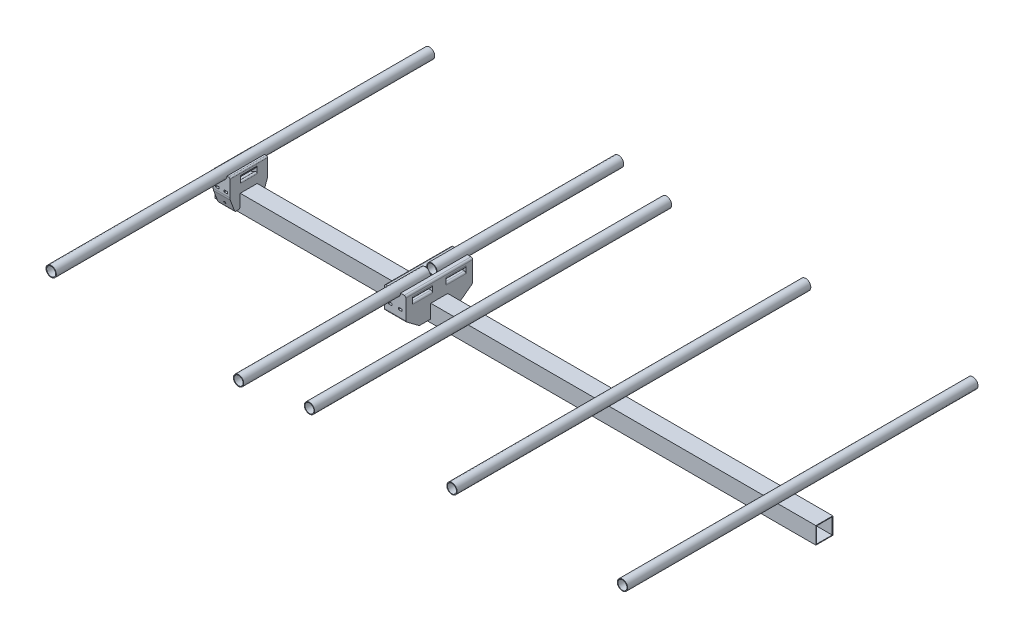
from build123d import *

# Parameters (mm, degrees)
SKETCH1_W                                      = 25.4
SKETCH1_H                                      = 25.4
SKETCH1_W_2                                    = 23.622
SKETCH1_H_2                                    = 23.622
AL_TUBE_SQUARE_AL_TUBE_1_SQR_X_0_035_WAL_DEPTH = 900
ELEMENT_GEOMETRY_R                             = 7.75
REFLECTOR_GEOMETRY_DEPTH                       = 283.5
ELEMENT_GEOMETRY_4_R                           = 7.75
DIRECTOR_GEOMETRY_1_DEPTH                      = 267.5
ELEMENT_GEOMETRY_5_R                           = 7.75
DIRECTOR_GEOMETRY_2_DEPTH                      = 265
ELEMENT_GEOMETRY_6_R                           = 7.75
DIRECTOR_GEOMETRY_3_DEPTH                      = 262.5
DIPOLE_A_START                                 = 5
ELEMENT_GEOMETRY_7_R                           = 7.75
DIPOLE_A_DEPTH                                 = 279.7
ELEMENT_BASE_DEPTH                             = 13.2
ELEMENT_BASE_DEPTH_BACK                        = 13.2
ELEMENT_BASE_SIDE_DEPTH                        = 15
CUT_EXTRUDE3_DEPTH                             = 12.5
SKETCH9_R                                      = 1.5
CUT_EXTRUDE4_DEPTH                             = 551.208733119
CUT_EXTRUDE4_DEPTH_BACK                        = 551.208733119
SKETCH10_W                                     = 5
SKETCH10_H                                     = 3
CUT_EXTRUDE5_DEPTH                             = 56.4
CUT_EXTRUDE6_DEPTH                             = 25
FILLET3_R                                      = 10
FILLET4_R                                      = 2
DIRECTOR_BASE_R                                = 2
BOSS_EXTRUDE8_DEPTH                            = 50
BOSS_EXTRUDE10_START                           = -127
BOSS_EXTRUDE10_DEPTH                           = 32
BOSS_EXTRUDE11_DEPTH                           = 32
BOSS_EXTRUDE11_2_DEPTH                         = 32
SKETCH18_W                                     = 30
SKETCH18_H                                     = 3
CUT_EXTRUDE7_DEPTH                             = 32
FILLET6_R                                      = 5
FILLET7_R                                      = 2.5
SKETCH21_W                                     = 5
SKETCH21_H                                     = 3
CUT_EXTRUDE8_DEPTH                             = 535.674976037
CUT_EXTRUDE8_DEPTH_BACK                        = 535.674976037
CUT_EXTRUDE10_DEPTH                            = 32
DIPOLE_BASE_R                                  = 2.5
SKETCH24_R                                     = 6.75
CUT_EXTRUDE11_DEPTH                            = 535.674976037
CUT_EXTRUDE11_DEPTH_BACK                       = 535.674976037


with BuildPart() as part:
    # Sketch1 → Al tube square AL TUBE 1 SQR X 0.035 WAL (new body)
    with BuildSketch(Plane(origin=(-450, 0, 0), x_dir=(0, 0, -1), z_dir=(1, 0, 0))):
        Rectangle(SKETCH1_W, SKETCH1_H)
        Rectangle(SKETCH1_W_2, SKETCH1_H_2, mode=Mode.SUBTRACT)
    extrude(amount=AL_TUBE_SQUARE_AL_TUBE_1_SQR_X_0_035_WAL_DEPTH)


with BuildPart() as body_2:
    # Element Geometry → Reflector Geometry (new, symmetric)
    with BuildSketch(Plane.XY):
        with Locations((-425, 40.45)):
            Circle(ELEMENT_GEOMETRY_R)
    extrude(amount=REFLECTOR_GEOMETRY_DEPTH, both=True)


with BuildPart() as body_3:
    # Element Geometry_4 → Director Geometry _1 (new, symmetric)
    with BuildSketch(Plane.XY):
        with Locations((-54, 40.45)):
            Circle(ELEMENT_GEOMETRY_4_R)
    extrude(amount=DIRECTOR_GEOMETRY_1_DEPTH, both=True)


with BuildPart() as body_4:
    # Element Geometry_5 → Director Geometry _2 (new, symmetric)
    with BuildSketch(Plane.XY):
        with Locations((157, 40.45)):
            Circle(ELEMENT_GEOMETRY_5_R)
    extrude(amount=DIRECTOR_GEOMETRY_2_DEPTH, both=True)


with BuildPart() as body_5:
    # Element Geometry_6 → Director Geometry _3 (new, symmetric)
    with BuildSketch(Plane.XY):
        with Locations((410, 40.45)):
            Circle(ELEMENT_GEOMETRY_6_R)
    extrude(amount=DIRECTOR_GEOMETRY_3_DEPTH, both=True)


with BuildPart() as body_6:
    # Element Geometry_7 → Dipole-A (new body)
    with BuildSketch(Plane.XY.offset(DIPOLE_A_START)):
        with Locations((-143, 40.45)):
            Circle(ELEMENT_GEOMETRY_7_R)
    extrude(amount=DIPOLE_A_DEPTH)


with BuildPart() as body_7:
    # Dipole-B: mirrored copy
    add(body_6.part.mirror(Plane.XY))


with BuildPart() as body_8:
    # Sketch3 → Element Base (new, two sides)
    with BuildSketch(Plane.XY) as element_base_sk:
        with BuildLine():
            Line((-433, 40.45), (-437.5, 40.45))
            Line((-437.5, 40.45), (-437.5, 12.7))
            Line((-437.5, 12.7), (-412.5, 12.7))
            Line((-412.5, 12.7), (-412.5, 40.45))
            Line((-412.5, 40.45), (-417, 40.45))
            ThreePointArc((-417, 40.45), (-425, 32.45), (-433, 40.45))
        make_face()
    extrude(amount=ELEMENT_BASE_DEPTH)
    extrude(element_base_sk.sketch, amount=-ELEMENT_BASE_DEPTH_BACK)


with BuildPart() as body_9:
    # Sketch4 → Element Base Side (new body)
    with BuildSketch(Plane.XY.offset(13.2)):
        with BuildLine():
            Line((-437.5, 12.7), (-437.5, -7.3))
            Line((-437.5, -7.3), (-412.5, -7.3))
            Line((-412.5, -7.3), (-412.5, 12.7))
            Line((-412.5, 12.7), (-412.5, 40.45))
            Line((-412.5, 40.45), (-417, 40.45))
            ThreePointArc((-417, 40.45), (-425, 32.45), (-433, 40.45))
            Line((-433, 40.45), (-437.5, 40.45))
            Line((-437.5, 40.45), (-437.5, 12.7))
        make_face()
    extrude(amount=ELEMENT_BASE_SIDE_DEPTH)


with BuildPart() as body_10:
    # Mirror3: mirrored copy
    add(body_9.part.mirror(Plane.XY))

    # Combine1: union body 8, body 9
    add(body_8.part)
    add(body_9.part)

    # Sketch8 → Cut-Extrude3 (cut, symmetric)
    with BuildSketch(Plane.XY):
        with BuildLine():
            Line((-412.5, 35.45), (-412.5, 29.736575146))
            ThreePointArc((-412.5, 29.736575146), (-425, 23.987087982), (-437.5, 29.736575146))
            Line((-437.5, 29.736575146), (-437.5, 35.45))
            ThreePointArc((-437.5, 35.45), (-425, 26.987087982), (-412.5, 35.45))
        make_face()
    extrude(amount=CUT_EXTRUDE3_DEPTH, both=True, mode=Mode.SUBTRACT)


with BuildPart() as cut_extrude4_tool:
    # Sketch9 → Cut-Extrude4 (new, two sides)
    with BuildSketch(Plane(origin=(0, 0, -28.2), x_dir=(-1, 0, 0), z_dir=(0, 0, -1))) as cut_extrude4_sk:
        with Locations(Location((425, 0, 0), (0, 0, 90))):
            Circle(SKETCH9_R)
    extrude(amount=CUT_EXTRUDE4_DEPTH)
    extrude(cut_extrude4_sk.sketch, amount=-CUT_EXTRUDE4_DEPTH_BACK)


with BuildPart() as part_1:
    add(part.part)

    # Cut-Extrude4: cut by cut_extrude4_tool
    add(cut_extrude4_tool.part, mode=Mode.SUBTRACT)


with BuildPart() as body_10_1:
    add(body_10.part)

    # Cut-Extrude4: cut by cut_extrude4_tool
    add(cut_extrude4_tool.part, mode=Mode.SUBTRACT)

    # Sketch10 → Cut-Extrude5 (cut)
    with BuildSketch(Plane.XY.offset(28.2)):
        with Locations((-418.75, 19.2)):
            Rectangle(SKETCH10_W, SKETCH10_H)
        with Locations((-431.25, 19.2)):
            Rectangle(SKETCH10_W, SKETCH10_H)
    extrude(amount=-CUT_EXTRUDE5_DEPTH, mode=Mode.SUBTRACT)

    # Sketch11 → Cut-Extrude6 (cut)
    with BuildSketch(Plane.ZY.offset(437.5)):
        Polygon((-20.7, -7.3), (-28.2, 12.7), (-28.2, -7.3), align=None)
        Polygon((28.2, -7.3), (20.7, -7.3), (28.2, 12.7), align=None)
    extrude(amount=-CUT_EXTRUDE6_DEPTH, mode=Mode.SUBTRACT)

    # Fillet3
    fillet3_edges = [body_10_1.edges().sort_by_distance(p)[0] for p in [
        (-425, 12.7, -28.2),
        (-425, 12.7, 28.2),
    ]]
    fillet(fillet3_edges, radius=FILLET3_R)

    # Fillet4
    fillet4_edges = [body_10_1.edges().sort_by_distance(p)[0] for p in [
        (-425, -7.3, -20.7),
        (-425, -7.3, 20.7),
        (-425, -7.3, 13.2),
        (-425, -7.3, -13.2),
    ]]
    fillet(fillet4_edges, radius=FILLET4_R)

    # Director Base
    director_base_edges = [body_10_1.edges().sort_by_distance(p)[0] for p in [
        (-412.5, 40.45, 0),
        (-437.5, 40.45, 0),
        (-437.5, 29.736575146, 0),
        (-412.5, 29.736575146, 0),
    ]]
    fillet(director_base_edges, radius=DIRECTOR_BASE_R)


with BuildPart() as body_9_2:
    # Sketch12 → Boss-Extrude8 (new, symmetric)
    with BuildSketch(Plane.XY):
        with BuildLine():
            Line((-127, 40.45), (-135, 40.45))
            ThreePointArc((-135, 40.45), (-143, 32.45), (-151, 40.45))
            Line((-151, 40.45), (-159, 40.45))
            Line((-159, 40.45), (-159, 15.45))
            Line((-159, 15.45), (-127, 15.45))
            Line((-127, 15.45), (-127, 40.45))
        make_face()
    extrude(amount=BOSS_EXTRUDE8_DEPTH, both=True)


with BuildPart() as body_10_2:
    # Sketch16 → Boss-Extrude10 (new body)
    with BuildSketch(Plane(origin=(0, 0, 0), x_dir=(0, 0, -1), z_dir=(1, 0, 0)).offset(BOSS_EXTRUDE10_START)):
        Polygon((13.2, 12.7), (-13.2, 12.7), (-13.2, -7.7), (-18.2, -7.7), (-23.2, -2.7), (-23.2, 15.45), (23.2, 15.45), (23.2, -2.7), (18.2, -7.7), (13.2, -7.7), align=None)
    extrude(amount=-BOSS_EXTRUDE10_DEPTH)


with BuildPart() as body_9_2_1:
    add(body_9_2.part)

    # Combine3: union body 10 2
    add(body_10_2.part)


with BuildPart() as body_10_3:
    # Sketch17 → Boss-Extrude11 (new body)
    with BuildSketch(Plane.ZY.offset(159)):
        Polygon((-18.2, -7.7), (-50, -7.7), (-50, 15.45), (-23.2, 15.45), (-23.2, -2.7), align=None)
    extrude(amount=-BOSS_EXTRUDE11_DEPTH)


with BuildPart() as body_11:
    # Sketch17 → Boss-Extrude11 2 (new body)
    with BuildSketch(Plane.ZY.offset(159)):
        Polygon((23.2, -2.7), (18.2, -7.7), (50, -7.7), (50, 15.45), (23.2, 15.45), align=None)
    extrude(amount=-BOSS_EXTRUDE11_2_DEPTH)

    # Combine4: union body 9 2, body 10 3
    add(body_9_2_1.part)
    add(body_10_3.part)

    # Sketch18 → Cut-Extrude7 (cut)
    with BuildSketch(Plane.ZY.offset(159)):
        with Locations((-25, 28.7)):
            Rectangle(SKETCH18_W, SKETCH18_H)
        with Locations((25, 28.7)):
            Rectangle(SKETCH18_W, SKETCH18_H)
    extrude(amount=-CUT_EXTRUDE7_DEPTH, mode=Mode.SUBTRACT)

    # Fillet6
    fillet6_edges = [body_11.edges().sort_by_distance(p)[0] for p in [
        (-127, 30.2, -25),
        (-159, 30.2, -25),
        (-127, 30.2, 25),
        (-159, 30.2, 25),
    ]]
    fillet(fillet6_edges, radius=FILLET6_R)

    # Fillet7
    fillet7_edges = [body_11.edges().sort_by_distance(p)[0] for p in [
        (-159, 40.45, 0),
        (-127, 40.45, 0),
        (-127, 27.2, -25),
        (-159, 27.2, -25),
        (-127, 27.2, 25),
        (-159, 27.2, 25),
    ]]
    fillet(fillet7_edges, radius=FILLET7_R)

    # Sketch21 → Cut-Extrude8 (cut, two sides)
    with BuildSketch(Plane.XY) as cut_extrude8_sk:
        with Locations((-150.5, 19.2)):
            Rectangle(SKETCH21_W, SKETCH21_H)
        with Locations((-135.5, 19.2)):
            Rectangle(SKETCH21_W, SKETCH21_H)
    extrude(amount=CUT_EXTRUDE8_DEPTH, mode=Mode.SUBTRACT)
    extrude(cut_extrude8_sk.sketch, amount=-CUT_EXTRUDE8_DEPTH_BACK, mode=Mode.SUBTRACT)

    # Sketch23 → Cut-Extrude10 (cut)
    with BuildSketch(Plane.ZY.offset(159)):
        Polygon((-50, 7.3), (-50, -7.7), (-30, -7.7), align=None)
        Polygon((50, -7.7), (30, -7.7), (50, 7.3), align=None)
    extrude(amount=-CUT_EXTRUDE10_DEPTH, mode=Mode.SUBTRACT)

    # Dipole Base
    dipole_base_edges = [body_11.edges().sort_by_distance(p)[0] for p in [
        (-143, 7.3, -50),
        (-143, -7.7, -30),
        (-143, 7.3, 50),
        (-143, -7.7, 30),
    ]]
    fillet(dipole_base_edges, radius=DIPOLE_BASE_R)


with BuildPart() as cut_extrude11_tool:
    # Sketch24 → Cut-Extrude11 (new, two sides)
    with BuildSketch(Plane.XY) as cut_extrude11_sk:
        with Locations((-425, 40.45)):
            Circle(SKETCH24_R)
        with Locations((410, 40.45)):
            Circle(SKETCH24_R)
        with Locations((-54, 40.45)):
            Circle(SKETCH24_R)
        with Locations((157, 40.45)):
            Circle(SKETCH24_R)
        with Locations((-143, 40.45)):
            Circle(SKETCH24_R)
    extrude(amount=CUT_EXTRUDE11_DEPTH)
    extrude(cut_extrude11_sk.sketch, amount=-CUT_EXTRUDE11_DEPTH_BACK)


with BuildPart() as body_2_1:
    add(body_2.part)

    # Cut-Extrude11: cut by cut_extrude11_tool
    add(cut_extrude11_tool.part, mode=Mode.SUBTRACT)


with BuildPart() as body_3_1:
    add(body_3.part)

    # Cut-Extrude11: cut by cut_extrude11_tool
    add(cut_extrude11_tool.part, mode=Mode.SUBTRACT)


with BuildPart() as body_4_1:
    add(body_4.part)

    # Cut-Extrude11: cut by cut_extrude11_tool
    add(cut_extrude11_tool.part, mode=Mode.SUBTRACT)


with BuildPart() as body_5_1:
    add(body_5.part)

    # Cut-Extrude11: cut by cut_extrude11_tool
    add(cut_extrude11_tool.part, mode=Mode.SUBTRACT)


with BuildPart() as body_6_1:
    add(body_6.part)

    # Cut-Extrude11: cut by cut_extrude11_tool
    add(cut_extrude11_tool.part, mode=Mode.SUBTRACT)


with BuildPart() as body_7_1:
    add(body_7.part)

    # Cut-Extrude11: cut by cut_extrude11_tool
    add(cut_extrude11_tool.part, mode=Mode.SUBTRACT)


solid = Compound([part_1.part, body_10_1.part, body_11.part, body_2_1.part, body_3_1.part, body_4_1.part, body_5_1.part, body_6_1.part, body_7_1.part])
